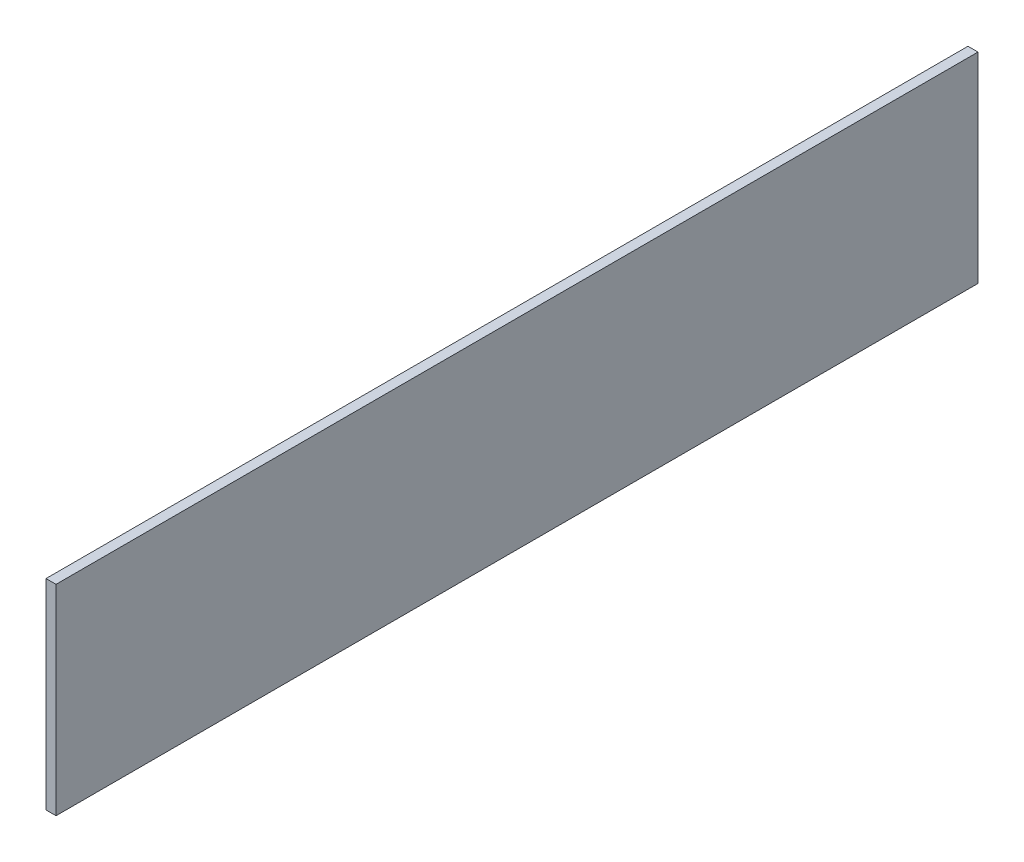
from build123d import *

# Parameters (mm, degrees)
ESBO_O1_W                = 2300
ESBO_O1_H                = 500
RESSALTO_EXTRUS_O1_DEPTH = 25


with BuildPart() as part:
    # Esboço1 → Ressalto-extrusão1 (new body)
    with BuildSketch(Plane(origin=(0, 0, 0), x_dir=(0, 0, -1), z_dir=(1, 0, 0))):
        with Locations((1150, 250)):
            Rectangle(ESBO_O1_W, ESBO_O1_H)
    extrude(amount=RESSALTO_EXTRUS_O1_DEPTH)


solid = part.part
